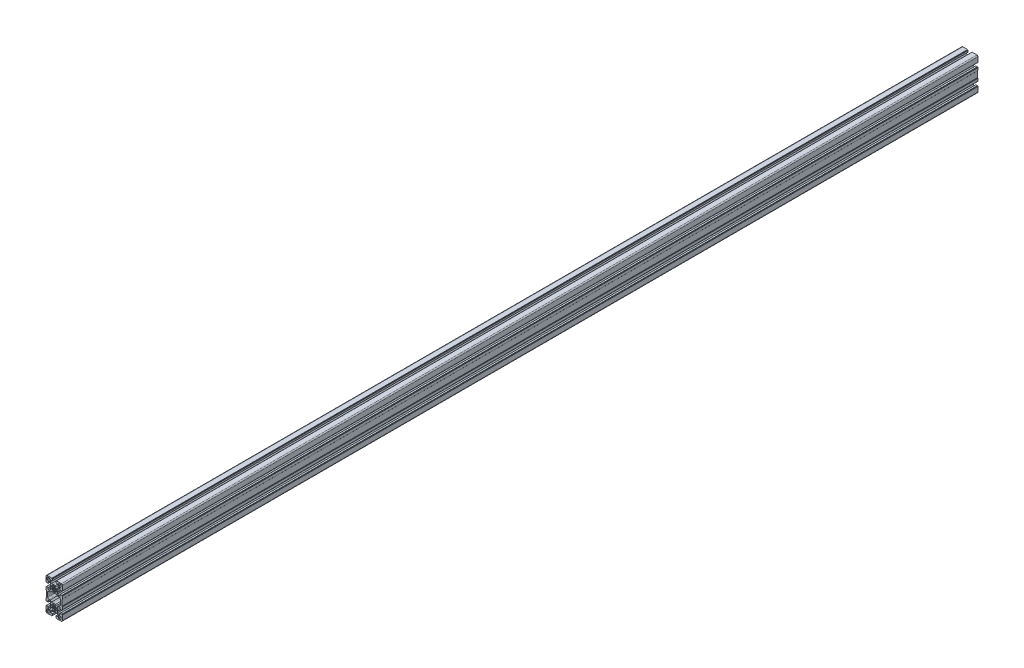
from build123d import *

# Parameters (mm, degrees)
BASE_EXTRUDE_DEPTH = 2525


with BuildPart() as part:
    # Sketch1 → Base-Extrude (new body)
    with BuildSketch(Plane.XY):
        with BuildLine():
            Line((22.499946974, -16.200158141), (22.499946974, -9.250057041))
            ThreePointArc((22.499946974, -9.250057041), (22.353500767, -8.896504248), (21.999947974, -8.750058041))
            Line((21.999947974, -8.750058041), (20.999949974, -8.750058041))
            Line((20.999949974, -8.750058041), (20.999949974, 8.749948959))
            Line((20.999949974, 8.749948959), (21.999947974, 8.749948959))
            ThreePointArc((21.999947974, 8.749948959), (22.353500767, 8.896395166), (22.499946974, 9.249947959))
            Line((22.499946974, 9.249947959), (22.499946974, 16.199923059))
            ThreePointArc((22.499946974, 16.199923059), (22.353500767, 16.553475852), (21.999947974, 16.699922059))
            Line((21.999947974, 16.699922059), (20.999945974, 16.699922059))
            Line((20.999945974, 16.699922059), (20.999945974, 17.500038322))
            Line((20.999945974, 17.500038322), (16.499984564, 17.500038322))
            Line((16.499984564, 17.500038322), (16.499984564, 12.450045422))
            Line((16.499984564, 12.450045422), (12.342903879, 12.450045422))
            Line((12.342903879, 12.450045422), (9.499939565, 15.293011736))
            Line((9.499939565, 15.293011736), (9.499939565, 19.377357567))
            ThreePointArc((9.499939565, 19.377357567), (9.999997173, 22.500024322), (9.499939565, 25.622691077))
            Line((9.499939565, 25.622691077), (9.499939565, 29.707040908))
            Line((9.499939565, 29.707040908), (12.342903879, 32.550007222))
            Line((12.342903879, 32.550007222), (16.499984564, 32.550007222))
            Line((16.499984564, 32.550007222), (16.499984564, 27.500010322))
            Line((16.499984564, 27.500010322), (20.999975564, 27.500010322))
            Line((20.999975564, 27.500010322), (20.999975564, 28.300016128))
            Line((20.999975564, 28.300016128), (21.999947974, 28.300016128))
            ThreePointArc((21.999947974, 28.300016128), (22.353500767, 28.446462335), (22.499946974, 28.800015128))
            Line((22.499946974, 28.800015128), (22.499946974, 42.000028423))
            ThreePointArc((22.499946974, 42.000028423), (21.621269732, 44.121342939), (19.499955216, 45.000020182))
            Line((19.499955216, 45.000020182), (6.3000381, 45.000020182))
            ThreePointArc((6.3000381, 45.000020182), (5.946485307, 44.853573975), (5.8000391, 44.500021182))
            Line((5.8000391, 44.500021182), (5.8000391, 43.499901622))
            Line((5.8000391, 43.499901622), (4.999946974, 43.499901622))
            Line((4.999946974, 43.499901622), (4.999946974, 38.999910622))
            Line((4.999946974, 38.999910622), (10.049915874, 38.999910622))
            Line((10.049915874, 38.999910622), (10.049915874, 34.842829936))
            Line((10.049915874, 34.842829936), (7.20694956, 31.999863622))
            Line((7.20694956, 31.999863622), (3.122605729, 31.999863622))
            ThreePointArc((3.122605729, 31.999863622), (-6.3026e-05, 32.499921551), (-3.12273178, 31.999863622))
            Line((-3.12273178, 31.999863622), (-7.207079612, 31.999863622))
            Line((-7.207079612, 31.999863622), (-10.050045926, 34.842829936))
            Line((-10.050045926, 34.842829936), (-10.050045926, 38.999910622))
            Line((-10.050045926, 38.999910622), (-5.000053026, 38.999910622))
            Line((-5.000053026, 38.999910622), (-5.000053026, 43.499901622))
            Line((-5.000053026, 43.499901622), (-5.800149622, 43.499901622))
            Line((-5.800149622, 43.499901622), (-5.800149622, 44.500022621))
            ThreePointArc((-5.800149622, 44.500022621), (-5.946596597, 44.853574536), (-6.300149062, 45.000020182))
            Line((-6.300149062, 45.000020182), (-19.500060267, 45.000020182))
            ThreePointArc((-19.500060267, 45.000020182), (-21.62137549, 44.121342646), (-22.500053026, 42.000027423))
            Line((-22.500053026, 42.000027423), (-22.500053026, 28.799755268))
            ThreePointArc((-22.500053026, 28.799755268), (-22.353606819, 28.446202475), (-22.000054026, 28.299756268))
            Line((-22.000054026, 28.299756268), (-20.999995026, 28.299756268))
            Line((-20.999995026, 28.299756268), (-20.999995026, 27.500258775))
            Line((-20.999995026, 27.500258775), (-16.500004026, 27.500258775))
            Line((-16.500004026, 27.500258775), (-16.500004026, 32.549762768))
            Line((-16.500004026, 32.549762768), (-12.34292134, 32.549762768))
            Line((-12.34292134, 32.549762768), (-9.499957026, 29.706796454))
            Line((-9.499957026, 29.706796454), (-9.499957026, 25.622446623))
            ThreePointArc((-9.499957026, 25.622446623), (-10.000014635, 22.499779868), (-9.499957026, 19.377113114))
            Line((-9.499957026, 19.377113114), (-9.499957026, 15.292763282))
            Line((-9.499957026, 15.292763282), (-12.34292134, 12.449796968))
            Line((-12.34292134, 12.449796968), (-16.500002026, 12.449796968))
            Line((-16.500002026, 12.449796968), (-16.500002026, 17.499789868))
            Line((-16.500002026, 17.499789868), (-20.999993026, 17.499789868))
            Line((-20.999993026, 17.499789868), (-20.999993026, 16.699796468))
            Line((-20.999993026, 16.699796468), (-22.000054026, 16.699796468))
            ThreePointArc((-22.000054026, 16.699796468), (-22.353606819, 16.553350261), (-22.500053026, 16.199797468))
            Line((-22.500053026, 16.199797468), (-22.500053026, 9.249951368))
            ThreePointArc((-22.500053026, 9.249951368), (-22.353606819, 8.896398575), (-22.000054026, 8.749952368))
            Line((-22.000054026, 8.749952368), (-21.000056026, 8.749952368))
            Line((-21.000056026, 8.749952368), (-21.000056026, -8.750054632))
            Line((-21.000056026, -8.750054632), (-22.000054026, -8.750054632))
            ThreePointArc((-22.000054026, -8.750054632), (-22.353606819, -8.896500839), (-22.500053026, -9.250053632))
            Line((-22.500053026, -9.250053632), (-22.500053026, -16.200025732))
            ThreePointArc((-22.500053026, -16.200025732), (-22.353606819, -16.553578525), (-22.000054026, -16.700024732))
            Line((-22.000054026, -16.700024732), (-20.999993026, -16.700024732))
            Line((-20.999993026, -16.700024732), (-20.999993026, -17.50000722))
            Line((-20.999993026, -17.50000722), (-16.500002026, -17.50000722))
            Line((-16.500002026, -17.50000722), (-16.500002026, -12.449992778))
            Line((-16.500002026, -12.449992778), (-12.342909022, -12.449992778))
            Line((-12.342909022, -12.449992778), (-9.499944708, -15.292959092))
            Line((-9.499944708, -15.292959092), (-9.499944708, -19.377306923))
            ThreePointArc((-9.499944708, -19.377306923), (-10.000002637, -22.499975678), (-9.499944708, -25.622644433))
            Line((-9.499944708, -25.622644433), (-9.499944708, -29.706988264))
            Line((-9.499944708, -29.706988264), (-12.342909022, -32.549954578))
            Line((-12.342909022, -32.549954578), (-16.499989708, -32.549954578))
            Line((-16.499989708, -32.549954578), (-16.499989708, -27.499944136))
            Line((-16.499989708, -27.499944136), (-20.999993889, -27.499944136))
            Line((-20.999993889, -27.499944136), (-20.999993889, -28.299934536))
            Line((-20.999993889, -28.299934536), (-22.000052889, -28.299934536))
            ThreePointArc((-22.000052889, -28.299934536), (-22.353606429, -28.44638094), (-22.500053026, -28.7999344))
            Line((-22.500053026, -28.7999344), (-22.500053026, -41.999988059))
            ThreePointArc((-22.500053026, -41.999988059), (-21.621375783, -44.121302575), (-19.500061267, -44.999979818))
            Line((-19.500061267, -44.999979818), (-6.300147471, -44.999979818))
            ThreePointArc((-6.300147471, -44.999979818), (-5.946595084, -44.853533984), (-5.800148297, -44.499981992))
            Line((-5.800148297, -44.499981992), (-5.800148297, -43.499983992))
            Line((-5.800148297, -43.499983992), (-5.000154897, -43.499983992))
            Line((-5.000154897, -43.499983992), (-5.000154897, -38.999959555))
            Line((-5.000154897, -38.999959555), (-10.05011844, -38.999959555))
            Line((-10.05011844, -38.999959555), (-10.05011844, -34.842878869))
            Line((-10.05011844, -34.842878869), (-7.207152126, -31.999914555))
            Line((-7.207152126, -31.999914555), (-3.122804295, -31.999914555))
            ThreePointArc((-3.122804295, -31.999914555), (-0.000136715, -32.499979818), (3.122533214, -31.999929223))
            Line((3.122533214, -31.999929223), (7.206877046, -31.999929223))
            Line((7.206877046, -31.999929223), (10.04984336, -34.842893537))
            Line((10.04984336, -34.842893537), (10.04984336, -39.000023818))
            Line((10.04984336, -39.000023818), (5.000048845, -39.000023818))
            Line((5.000048845, -39.000023818), (5.000048845, -43.500014818))
            Line((5.000048845, -43.500014818), (5.799938374, -43.500014818))
            Line((5.799938374, -43.500014818), (5.799938374, -44.499980818))
            ThreePointArc((5.799938374, -44.499980818), (5.946384582, -44.853533611), (6.299937374, -44.999979818))
            Line((6.299937374, -44.999979818), (19.499955216, -44.999979818))
            ThreePointArc((19.499955216, -44.999979818), (21.621269732, -44.121302575), (22.499946974, -41.999988059))
            Line((22.499946974, -41.999988059), (22.499946974, -28.800163672))
            ThreePointArc((22.499946974, -28.800163672), (22.353500767, -28.446610879), (21.999947974, -28.300164672))
            Line((21.999947974, -28.300164672), (20.999949974, -28.300164672))
            Line((20.999949974, -28.300164672), (20.999949974, -27.500123541))
            Line((20.999949974, -27.500123541), (16.5000557, -27.500123541))
            Line((16.5000557, -27.500123541), (16.5000557, -32.550116441))
            Line((16.5000557, -32.550116441), (12.342975014, -32.550116441))
            Line((12.342975014, -32.550116441), (9.5000107, -29.707150127))
            Line((9.5000107, -29.707150127), (9.5000107, -25.622802296))
            ThreePointArc((9.5000107, -25.622802296), (10.000068629, -22.500133541), (9.5000107, -19.377464786))
            Line((9.5000107, -19.377464786), (9.5000107, -15.293120955))
            Line((9.5000107, -15.293120955), (12.342975014, -12.450154641))
            Line((12.342975014, -12.450154641), (16.5000557, -12.450154641))
            Line((16.5000557, -12.450154641), (16.5000557, -17.499827815))
            Line((16.5000557, -17.499827815), (21.0000467, -17.499827815))
            Line((21.0000467, -17.499827815), (21.0000467, -16.700157141))
            Line((21.0000467, -16.700157141), (21.999947974, -16.700157141))
            ThreePointArc((21.999947974, -16.700157141), (22.353500767, -16.553710934), (22.499946974, -16.200158141))
        make_face()
        with BuildLine():
            Line((-18.499896829, 34.499929), (-12.999907829, 34.499929))
            ThreePointArc((-12.999907829, 34.499929), (-12.292802243, 34.792821414), (-11.999909829, 35.499927))
            Line((-11.999909829, 35.499927), (-11.999909829, 40.999916))
            ThreePointArc((-11.999909829, 40.999916), (-12.292802243, 41.707021586), (-12.999907829, 41.999914))
            Line((-12.999907829, 41.999914), (-18.499896829, 41.999914))
            ThreePointArc((-18.499896829, 41.999914), (-19.207002415, 41.707021586), (-19.499894829, 40.999916))
            Line((-19.499894829, 40.999916), (-19.499894829, 35.499927))
            ThreePointArc((-19.499894829, 35.499927), (-19.207002415, 34.792821414), (-18.499896829, 34.499929))
        make_face(mode=Mode.SUBTRACT)
        with BuildLine():
            Line((2.867874003, -26.595836614), (4.588596972, -29.053277429))
            ThreePointArc((4.588596972, -29.053277429), (3.061458591, -29.891094572), (1.389182647, -30.378518785))
            Line((1.389182647, -30.378518785), (0.868254688, -27.424107693))
            ThreePointArc((0.868254688, -27.424107693), (2.382e-06, -27.500071088), (-0.868249924, -27.424107693))
            Line((-0.868249924, -27.424107693), (-1.389178731, -30.378529597))
            ThreePointArc((-1.389178731, -30.378529597), (-3.061454076, -29.891105713), (-4.588591855, -29.05328886))
            Line((-4.588591855, -29.05328886), (-2.867863296, -26.595840775))
            ThreePointArc((-2.867863296, -26.595840775), (-3.535517947, -26.03561465), (-4.095746672, -25.367962181))
            Line((-4.095746672, -25.367962181), (-6.553202946, -27.088685872))
            ThreePointArc((-6.553202946, -27.088685872), (-7.391022139, -25.561545127), (-7.878447296, -23.889266271))
            Line((-7.878447296, -23.889266271), (-4.924028205, -23.368313313))
            ThreePointArc((-4.924028205, -23.368313313), (-4.999988152, -22.500076972), (-4.924026961, -21.63184074))
            Line((-4.924026961, -21.63184074), (-7.878440072, -21.110894778))
            ThreePointArc((-7.878440072, -21.110894778), (-7.391015025, -19.438614922), (-6.553195722, -17.911473177))
            Line((-6.553195722, -17.911473177), (-4.095741637, -19.632191736))
            ThreePointArc((-4.095741637, -19.632191736), (-3.53551822, -18.96454673), (-2.867871119, -18.404325809))
            Line((-2.867871119, -18.404325809), (-4.588594812, -15.946884672))
            ThreePointArc((-4.588594812, -15.946884672), (-3.061451677, -15.109064205), (-1.389170211, -14.621638322))
            Line((-1.389170211, -14.621638322), (-0.868244253, -17.576052413))
            ThreePointArc((-0.868244253, -17.576052413), (8.141e-06, -17.500090019), (0.86826036, -17.576054413))
            Line((0.86826036, -17.576054413), (1.389188318, -14.621640322))
            ThreePointArc((1.389188318, -14.621640322), (3.061466564, -15.109064534), (4.588606919, -15.946882672))
            Line((4.588606919, -15.946882672), (2.867878528, -18.404327661))
            ThreePointArc((2.867878528, -18.404327661), (3.535527634, -18.96455138), (4.095752094, -19.632199865))
            Line((4.095752094, -19.632199865), (6.553197031, -17.91147951))
            ThreePointArc((6.553197031, -17.91147951), (7.391012024, -19.438621412), (7.878433042, -21.110900426))
            Line((7.878433042, -21.110900426), (4.924032969, -21.631847793))
            ThreePointArc((4.924032969, -21.631847793), (4.999992917, -22.500080553), (4.924032969, -23.368313313))
            Line((4.924032969, -23.368313313), (7.878447215, -23.88926018))
            ThreePointArc((7.878447215, -23.88926018), (7.391021206, -25.561541286), (6.553200487, -27.08868393))
            Line((6.553200487, -27.08868393), (4.095746402, -25.367969371))
            ThreePointArc((4.095746402, -25.367969371), (3.535522172, -26.035615189), (2.867874003, -26.595836614))
        make_face(mode=Mode.SUBTRACT)
        with BuildLine():
            Line((-18.499896829, -34.500055), (-12.999907829, -34.500055))
            ThreePointArc((-12.999907829, -34.500055), (-12.292802243, -34.792947414), (-11.999909829, -35.500053))
            Line((-11.999909829, -35.500053), (-11.999909829, -41.000042))
            ThreePointArc((-11.999909829, -41.000042), (-12.292802243, -41.707147586), (-12.999907829, -42.00004))
            Line((-12.999907829, -42.00004), (-18.499896829, -42.00004))
            ThreePointArc((-18.499896829, -42.00004), (-19.207002415, -41.707147586), (-19.499894829, -41.000042))
            Line((-19.499894829, -41.000042), (-19.499894829, -35.500053))
            ThreePointArc((-19.499894829, -35.500053), (-19.207002415, -34.792947414), (-18.499896829, -34.500055))
        make_face(mode=Mode.SUBTRACT)
        with BuildLine():
            Line((12.999978171, -34.500055), (18.499967171, -34.500055))
            ThreePointArc((18.499967171, -34.500055), (19.207072757, -34.792947414), (19.499965171, -35.500053))
            Line((19.499965171, -35.500053), (19.499965171, -41.000042))
            ThreePointArc((19.499965171, -41.000042), (19.207072757, -41.707147586), (18.499967171, -42.00004))
            Line((18.499967171, -42.00004), (12.999978171, -42.00004))
            ThreePointArc((12.999978171, -42.00004), (12.292872585, -41.707147586), (11.999980171, -41.000042))
            Line((11.999980171, -41.000042), (11.999980171, -35.500053))
            ThreePointArc((11.999980171, -35.500053), (12.292872585, -34.792947414), (12.999978171, -34.500055))
        make_face(mode=Mode.SUBTRACT)
        with BuildLine():
            Line((2.867897068, 26.595703255), (4.588619528, 29.053138344))
            ThreePointArc((4.588619528, 29.053138344), (3.061475238, 29.890962927), (1.389191401, 30.378391364))
            Line((1.389191401, 30.378391364), (0.868263443, 27.423983273))
            ThreePointArc((0.868263443, 27.423983273), (9.492e-06, 27.499946811), (-0.868244458, 27.423983273))
            Line((-0.868244458, 27.423983273), (-1.389172416, 30.378399364))
            ThreePointArc((-1.389172416, 30.378399364), (-3.061446691, 29.890974364), (-4.588583361, 29.053156975))
            Line((-4.588583361, 29.053156975), (-2.867858874, 26.595716706))
            ThreePointArc((-2.867858874, 26.595716706), (-3.535516892, 26.035488238), (-4.0957482, 25.367832604))
            Line((-4.0957482, 25.367832604), (-6.553205158, 27.088555774))
            ThreePointArc((-6.553205158, 27.088555774), (-7.391024241, 25.561416028), (-7.878449507, 23.889138172))
            Line((-7.878449507, 23.889138172), (-4.924030416, 23.368181214))
            ThreePointArc((-4.924030416, 23.368181214), (-4.999990508, 22.499946811), (-4.924030416, 21.631712407))
            Line((-4.924030416, 21.631712407), (-7.878443507, 21.110762449))
            ThreePointArc((-7.878443507, 21.110762449), (-7.391018241, 19.438484593), (-6.553199158, 17.911344848))
            Line((-6.553199158, 17.911344848), (-4.095750173, 19.632063835))
            ThreePointArc((-4.095750173, 19.632063835), (-3.535523098, 18.96441159), (-2.867870436, 18.404185012))
            Line((-2.867870436, 18.404185012), (-4.588595017, 15.946740607))
            ThreePointArc((-4.588595017, 15.946740607), (-3.061451881, 15.108920141), (-1.389170416, 14.621494258))
            Line((-1.389170416, 14.621494258), (-0.868244458, 17.575910349))
            ThreePointArc((-0.868244458, 17.575910349), (9.492e-06, 17.499946811), (0.868263443, 17.575910349))
            Line((0.868263443, 17.575910349), (1.389191401, 14.621498258))
            ThreePointArc((1.389191401, 14.621498258), (3.061468943, 15.108922178), (4.588608754, 15.946739733))
            Line((4.588608754, 15.946739733), (2.867882268, 18.404180003))
            ThreePointArc((2.867882268, 18.404180003), (3.53553764, 18.964407146), (4.095766958, 19.632060693))
            Line((4.095766958, 19.632060693), (6.553215043, 17.911341135))
            ThreePointArc((6.553215043, 17.911341135), (7.391034316, 19.438483177), (7.878459316, 21.110763304))
            Line((7.878459316, 21.110763304), (4.924049401, 21.631712407))
            ThreePointArc((4.924049401, 21.631712407), (5.000009492, 22.499946811), (4.924049401, 23.368181214))
            Line((4.924049401, 23.368181214), (7.878466163, 23.889124525))
            ThreePointArc((7.878466163, 23.889124525), (7.391040314, 25.561405863), (6.553220022, 27.088548945))
            Line((6.553220022, 27.088548945), (4.095765937, 25.367834387))
            ThreePointArc((4.095765937, 25.367834387), (3.535543398, 26.035480717), (2.867897068, 26.595703255))
        make_face(mode=Mode.SUBTRACT)
        with BuildLine():
            Line((-3.122395584, -12.999945), (-7.507369814, -12.999945))
            Line((-7.507369814, -12.999945), (-11.057332714, -9.4499801))
            Line((-11.057332714, -9.4499801), (-13.999967829, -9.4499801))
            ThreePointArc((-13.999967829, -9.4499801), (-16.828389672, -8.278410236), (-17.999958829, -5.4499881))
            Line((-17.999958829, -5.4499881), (-17.999958829, 5.4499881))
            ThreePointArc((-17.999958829, 5.4499881), (-16.828389672, 8.278410236), (-13.999967829, 9.4499801))
            Line((-13.999967829, 9.4499801), (-11.057332714, 9.4499801))
            Line((-11.057332714, 9.4499801), (-7.507369814, 12.999945))
            Line((-7.507369814, 12.999945), (-3.122400584, 12.999945))
            ThreePointArc((-3.122400584, 12.999945), (9.6315e-05, 12.49997556), (3.122583926, 13.000003))
            Line((3.122583926, 13.000003), (7.507352157, 13.000003))
            Line((7.507352157, 13.000003), (11.057369155, 9.450036198))
            Line((11.057369155, 9.450036198), (14.000001269, 9.450036198))
            ThreePointArc((14.000001269, 9.450036198), (16.828463281, 8.278426874), (17.999993269, 5.449932002))
            Line((17.999993269, 5.449932002), (17.999993269, -5.450044198))
            ThreePointArc((17.999993269, -5.450044198), (16.828423612, -8.278466541), (14.000001269, -9.450036198))
            Line((14.000001269, -9.450036198), (11.057369155, -9.450036198))
            Line((11.057369155, -9.450036198), (7.507352157, -13.000003))
            Line((7.507352157, -13.000003), (3.122577926, -13.000003))
            ThreePointArc((3.122577926, -13.000003), (9.5815e-05, -12.499976441), (-3.122395584, -12.999945))
        make_face(mode=Mode.SUBTRACT)
        with BuildLine():
            Line((11.999980171, 40.999916), (11.999980171, 35.499927))
            ThreePointArc((11.999980171, 35.499927), (12.292872585, 34.792821414), (12.999978171, 34.499929))
            Line((12.999978171, 34.499929), (18.499967171, 34.499929))
            ThreePointArc((18.499967171, 34.499929), (19.207072757, 34.792821414), (19.499965171, 35.499927))
            Line((19.499965171, 35.499927), (19.499965171, 40.999916))
            ThreePointArc((19.499965171, 40.999916), (19.207072757, 41.707021586), (18.499967171, 41.999914))
            Line((18.499967171, 41.999914), (12.999978171, 41.999914))
            ThreePointArc((12.999978171, 41.999914), (12.292872585, 41.707021586), (11.999980171, 40.999916))
        make_face(mode=Mode.SUBTRACT)
    extrude(amount=-BASE_EXTRUDE_DEPTH)


solid = part.part
